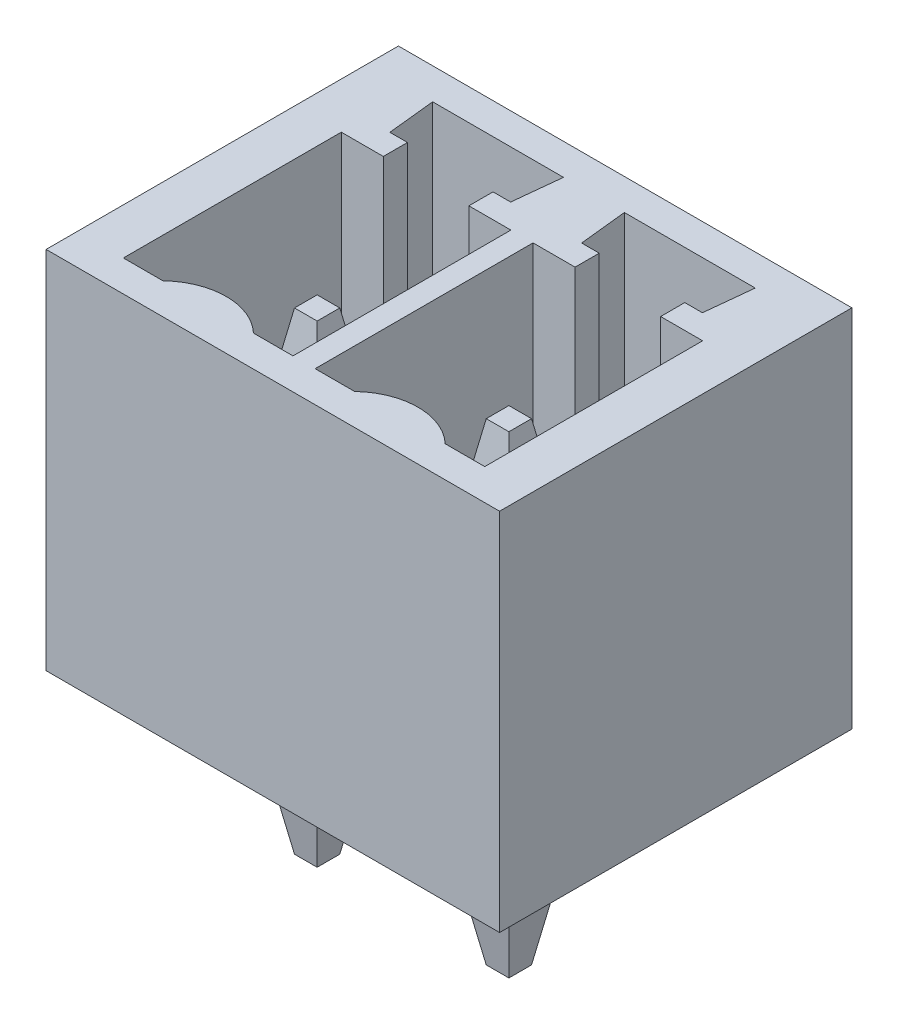
from build123d import *

# Parameters (mm, degrees)
SKETCH1_W                = 9.01
SKETCH1_H                = 7
BOSS_EXTRUDE1_DEPTH      = 7.25
CUT_EXTRUDE1_DEPTH       = 5.45
SKETCH3_W                = 0.85
SKETCH3_H                = 0.85
CUT_EXTRUDE2_DEPTH       = 2.8
LPATTERN1_COUNT          = 2
LPATTERN1_PITCH          = 3.81
SKETCH4_W                = 0.85
SKETCH4_H                = 0.85
BOSS_EXTRUDE2_DEPTH      = 4.35
BOSS_EXTRUDE2_DEPTH_BACK = 5.05
CHAMFER1_SIZE            = 0.2
CHAMFER1_SIZE2           = 1.134256364
CHAMFER1_PART_2_SIZE     = 0.2
CHAMFER1_PART_2_SIZE2    = 1.134256364
LPATTERN2_COUNT          = 2
LPATTERN2_PITCH          = 3.81


with BuildPart() as part:
    # Sketch1 → Boss-Extrude1 (new body)
    with BuildSketch(Plane(origin=(0, 0, 0), x_dir=(1, 0, 0), z_dir=(0, 1, 0))):
        Rectangle(SKETCH1_W, SKETCH1_H)
    extrude(amount=BOSS_EXTRUDE1_DEPTH)

    # Sketch2 → Cut-Extrude1 (cut)
    with BuildSketch(Plane(origin=(0, 7.25, 0), x_dir=(1, 0, 0), z_dir=(0, 1, 0))):
        with BuildLine():
            Line((-3.59, -2.88), (-3.59, 1.45))
            Line((-3.59, 1.45), (-2.755, 1.45))
            Line((-2.755, 1.45), (-2.755, 1.93))
            Line((-2.755, 1.93), (-3.105, 1.93))
            Line((-3.105, 1.93), (-3.205, 2.88))
            Line((-3.205, 2.88), (-0.605, 2.88))
            Line((-0.605, 2.88), (-0.705, 1.93))
            Line((-0.705, 1.93), (-1.055, 1.93))
            Line((-1.055, 1.93), (-1.055, 1.45))
            Line((-1.055, 1.45), (-0.22, 1.45))
            Line((-0.22, 1.45), (-0.22, -2.88))
            Line((-0.22, -2.88), (-1.005, -2.88))
            ThreePointArc((-1.005, -2.88), (-1.905, -2.52), (-2.805, -2.88))
            Line((-2.805, -2.88), (-3.59, -2.88))
        make_face()
    cut_extrude1 = extrude(amount=-CUT_EXTRUDE1_DEPTH, mode=Mode.SUBTRACT)

    # Sketch3 → Cut-Extrude2 (cut, through all)
    with BuildSketch(Plane(origin=(0, 1.8, 0), x_dir=(1, 0, 0), z_dir=(0, 1, 0))):
        with Locations((-1.905, -0.715)):
            Rectangle(SKETCH3_W, SKETCH3_H)
    cut_extrude2 = extrude(amount=-CUT_EXTRUDE2_DEPTH, mode=Mode.SUBTRACT)

    # LPattern1: Cut-Extrude1, Cut-Extrude2 ×2
    with Locations(*[(i * LPATTERN1_PITCH, 0, 0) for i in range(1, LPATTERN1_COUNT)]):
        add(cut_extrude1, mode=Mode.SUBTRACT)
        add(cut_extrude2, mode=Mode.SUBTRACT)


with BuildPart() as body_2:
    # Sketch4 → Boss-Extrude2 (new body, two sides)
    with BuildSketch(Plane(origin=(0, 1.8, 0), x_dir=(1, 0, 0), z_dir=(0, 1, 0))) as boss_extrude2_sk:
        with Locations((-1.905, -0.715)):
            Rectangle(SKETCH4_W, SKETCH4_H)
    extrude(amount=BOSS_EXTRUDE2_DEPTH)
    extrude(boss_extrude2_sk.sketch, amount=-BOSS_EXTRUDE2_DEPTH_BACK)

    # Chamfer1
    chamfer1_edges = [body_2.edges().sort_by_distance(p)[0] for p in [
        (-1.48, -3.25, 0.715),
        (-1.905, -3.25, 0.29),
        (-2.33, -3.25, 0.715),
        (-1.905, -3.25, 1.14),
    ]]
    chamfer1_side = [body_2.faces().sort_by_distance(p)[0] for p in [
        (-1.905, -3.25, 0.715),
    ]]
    chamfer(chamfer1_edges, length=CHAMFER1_SIZE, length2=CHAMFER1_SIZE2, reference=chamfer1_side[0])

    # Chamfer1 part 2
    chamfer1_part_2_edges = [body_2.edges().sort_by_distance(p)[0] for p in [
        (-1.905, 6.15, 0.29),
        (-1.48, 6.15, 0.715),
        (-1.905, 6.15, 1.14),
        (-2.33, 6.15, 0.715),
    ]]
    chamfer1_part_2_side = [body_2.faces().sort_by_distance(p)[0] for p in [
        (-1.905, 6.15, 0.715),
    ]]
    chamfer(chamfer1_part_2_edges, length=CHAMFER1_PART_2_SIZE, length2=CHAMFER1_PART_2_SIZE2, reference=chamfer1_part_2_side[0])


with BuildPart() as lpattern2_1:
    # LPattern2: pattern copy
    add(body_2.part.moved(Location(Vector(1, 0, 0) * (1 * LPATTERN2_PITCH))))


solid = Compound([part.part, body_2.part, lpattern2_1.part])
